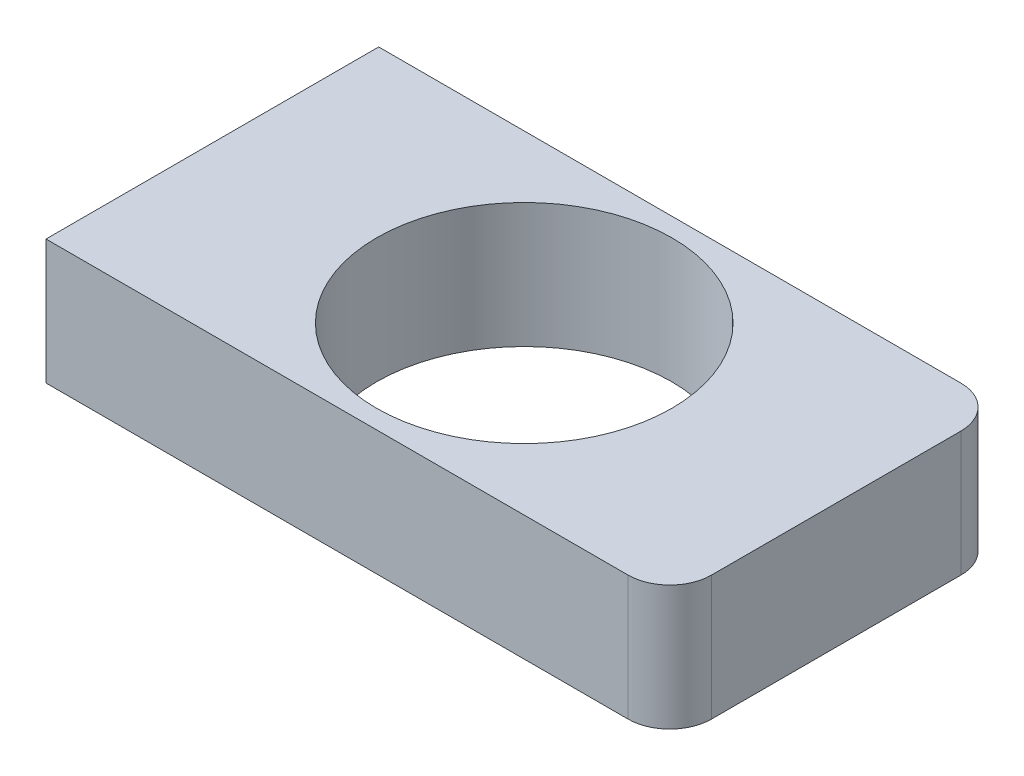
from build123d import *

# Parameters (mm, degrees)
SKETCH1_W           = 150
SKETCH1_H           = 80
BOSS_EXTRUDE1_DEPTH = 15
SKETCH2_R           = 35.508350292
CUT_EXTRUDE1_DEPTH  = 31
FILLET1_R           = 10


with BuildPart() as part:
    # Sketch1 → Boss-Extrude1 (new body, symmetric)
    with BuildSketch(Plane(origin=(0, 0, 0), x_dir=(1, 0, 0), z_dir=(0, 1, 0))):
        Rectangle(SKETCH1_W, SKETCH1_H)
    extrude(amount=BOSS_EXTRUDE1_DEPTH, both=True)

    # Sketch2 → Cut-Extrude1 (cut, through all)
    with BuildSketch(Plane(origin=(0, 15, 0), x_dir=(1, 0, 0), z_dir=(0, 1, 0))):
        Circle(SKETCH2_R)
    extrude(amount=-CUT_EXTRUDE1_DEPTH, mode=Mode.SUBTRACT)

    # Fillet1
    fillet1_edges = [part.edges().sort_by_distance(p)[0] for p in [
        (75, 0, 40),
        (75, 0, -40),
    ]]
    fillet(fillet1_edges, radius=FILLET1_R)


solid = part.part
